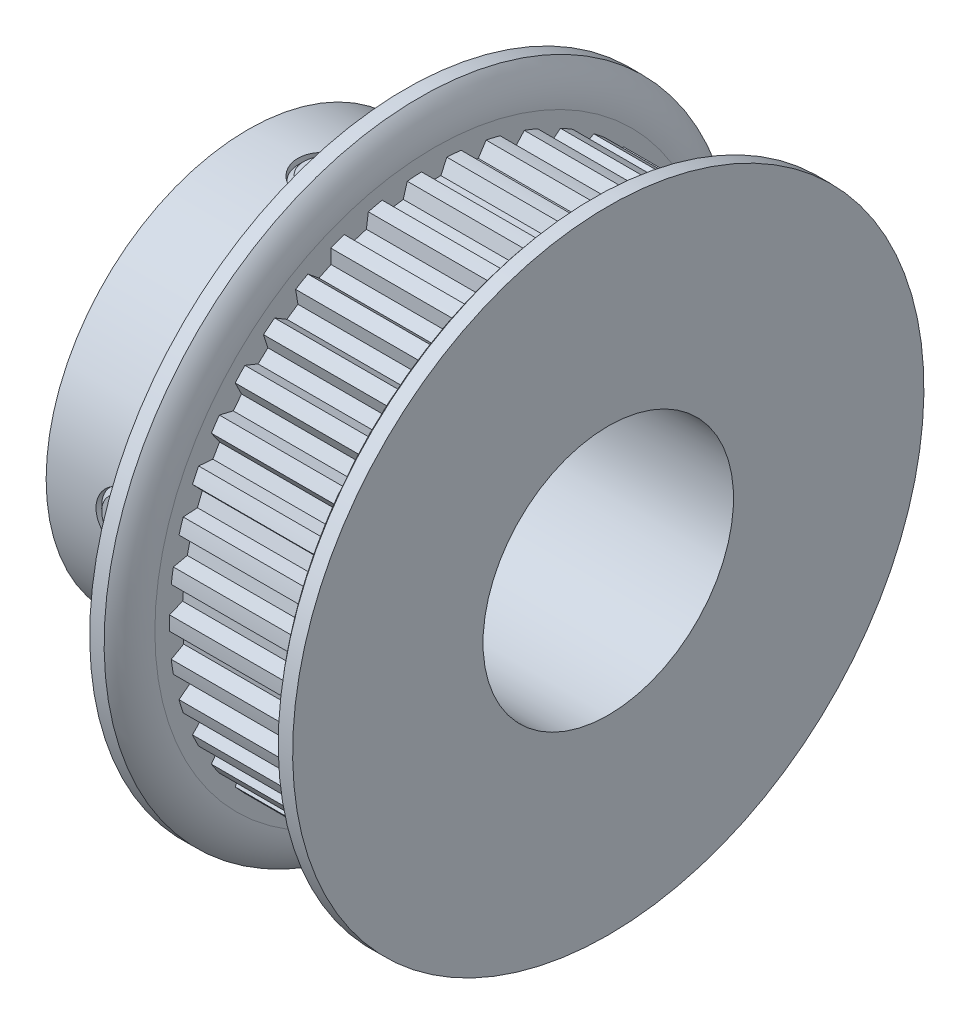
from build123d import *

# Parameters (mm, degrees)
SKETCH4_R          = 13.589
SKETCH4_R_2        = 13.43025
CUT_EXTRUDE2_DEPTH = 7.366
CUT_EXTRUDE1_DEPTH = 7.366
CIRPATTERN1_COUNT  = 42
SKETCH6_R          = 1.4605
CUT_EXTRUDE3_DEPTH = 25.403045869
CUT_EXTRUDE4_DEPTH = 1.016
CIRPATTERN2_COUNT  = 2
CIRPATTERN2_ANGLE  = 90
CIRPATTERN3_COUNT  = 2
CIRPATTERN3_ANGLE  = 90


with BuildPart() as part:
    # Sketch1 → Revolve1 (revolve)
    with BuildSketch(Plane.XY, mode=Mode.PRIVATE) as revolve1_sk:
        with BuildLine():
            Line((-9.1313, 6.35), (9.1313, 6.35))
            Line((9.1313, 6.35), (9.1313, 16.002))
            Line((9.1313, 16.002), (8.40105, 16.002))
            ThreePointArc((8.40105, 16.002), (7.860025322, 15.151003321), (7.6708, 14.1605))
            Line((7.6708, 14.1605), (7.6708, 13.589))
            Line((7.6708, 13.589), (0.3048, 13.589))
            Line((0.3048, 13.589), (0.3048, 14.1605))
            ThreePointArc((0.3048, 14.1605), (0.115574678, 15.151003321), (-0.42545, 16.002))
            Line((-0.42545, 16.002), (-1.1557, 16.002))
            Line((-1.1557, 16.002), (-1.1557, 10.2362))
            Line((-1.1557, 10.2362), (-9.1313, 10.2362))
            Line((-9.1313, 10.2362), (-9.1313, 6.35))
        make_face()
    revolve(revolve1_sk.sketch.rotate(Axis((-9.1313, 0, 0), (1, 0, 0)), 180), axis=Axis((-9.1313, 0, 0), (1, 0, 0)))

    # Sketch4 → Cut-Extrude2 (cut)
    with BuildSketch(Plane(origin=(0.3048, 0, 0), x_dir=(0, 0, -1), z_dir=(1, 0, 0))):
        Circle(SKETCH4_R)
        with Locations(Location((0, 0, 0), (0, 0, 90))):
            Circle(SKETCH4_R_2, mode=Mode.SUBTRACT)
    extrude(amount=CUT_EXTRUDE2_DEPTH, mode=Mode.SUBTRACT)

    # Sketch3 → Cut-Extrude1 (cut)
    with BuildSketch(Plane(origin=(0.3048, 0, 0), x_dir=(0, 0, -1), z_dir=(1, 0, 0))):
        with BuildLine():
            Line((-0.644061449, 13.414797796), (-0.338265727, 12.759016755))
            Line((-0.338265727, 12.759016755), (0.338265727, 12.759016755))
            Line((0.338265727, 12.759016755), (0.644061449, 13.414797796))
            ThreePointArc((0.644061449, 13.414797796), (0, 13.43025), (-0.644061449, 13.414797796))
        make_face()
    cut_extrude1 = extrude(amount=CUT_EXTRUDE1_DEPTH, mode=Mode.SUBTRACT)

    # CirPattern1: Cut-Extrude1 ×42 about axis
    cirpattern1_axis = Axis((0, 0, 0), (1, 0, 0))
    for i in range(1, CIRPATTERN1_COUNT):
        add(cut_extrude1.rotate(cirpattern1_axis, i * 360 / CIRPATTERN1_COUNT), mode=Mode.SUBTRACT)

    # Sketch6 → Cut-Extrude3 (cut, through all)
    with BuildSketch(Plane(origin=(0, 0, 0), x_dir=(1, 0, 0), z_dir=(0, 1, 0))):
        with Locations(Location((-5.1435, 0, 0), (0, 0, 90))):
            Circle(SKETCH6_R)
    cut_extrude3 = extrude(amount=CUT_EXTRUDE3_DEPTH, mode=Mode.SUBTRACT)

    # CirPattern2: Cut-Extrude3 ×2 about axis
    cirpattern2_axis = Axis((-9.1313, 0, 0), (1, 0, 0))
    for i in range(1, CIRPATTERN2_COUNT):
        add(cut_extrude3.rotate(cirpattern2_axis, i * CIRPATTERN2_ANGLE / (CIRPATTERN2_COUNT - 1)), mode=Mode.SUBTRACT)


with BuildPart() as body_2:
    # Sketch7 → Revolve2 (revolve)
    with BuildSketch(Plane.XY, mode=Mode.PRIVATE) as revolve2_sk:
        Polygon((-6.3119, 10.2362), (-5.1435, 10.2362), (-5.1435, 6.731), (-6.3119, 6.731), (-6.5659, 6.985), (-6.5659, 9.9822), align=None)
    revolve(revolve2_sk.sketch.rotate(Axis((-5.1435, 6.731, 0), (0, 1, 0)), 180), axis=Axis((-5.1435, 6.731, 0), (0, 1, 0)))

    # Sketch8 → Cut-Extrude4 (cut)
    with BuildSketch(Plane(origin=(0, 10.2362, 0), x_dir=(1, 0, 0), z_dir=(0, 1, 0))):
        Polygon((-5.1435, 0.821223023), (-5.8547, 0.410611511), (-5.8547, -0.410611511), (-5.1435, -0.821223023), (-4.4323, -0.410611511), (-4.4323, 0.410611511), align=None)
    extrude(amount=-CUT_EXTRUDE4_DEPTH, mode=Mode.SUBTRACT)


with BuildPart() as cirpattern3_1:
    # CirPattern3: pattern copy
    add(body_2.part.rotate(Axis((0, 0, 0), (1, 0, 0)), 1 * CIRPATTERN3_ANGLE / (CIRPATTERN3_COUNT - 1)))


solid = Compound([part.part, body_2.part, cirpattern3_1.part])
